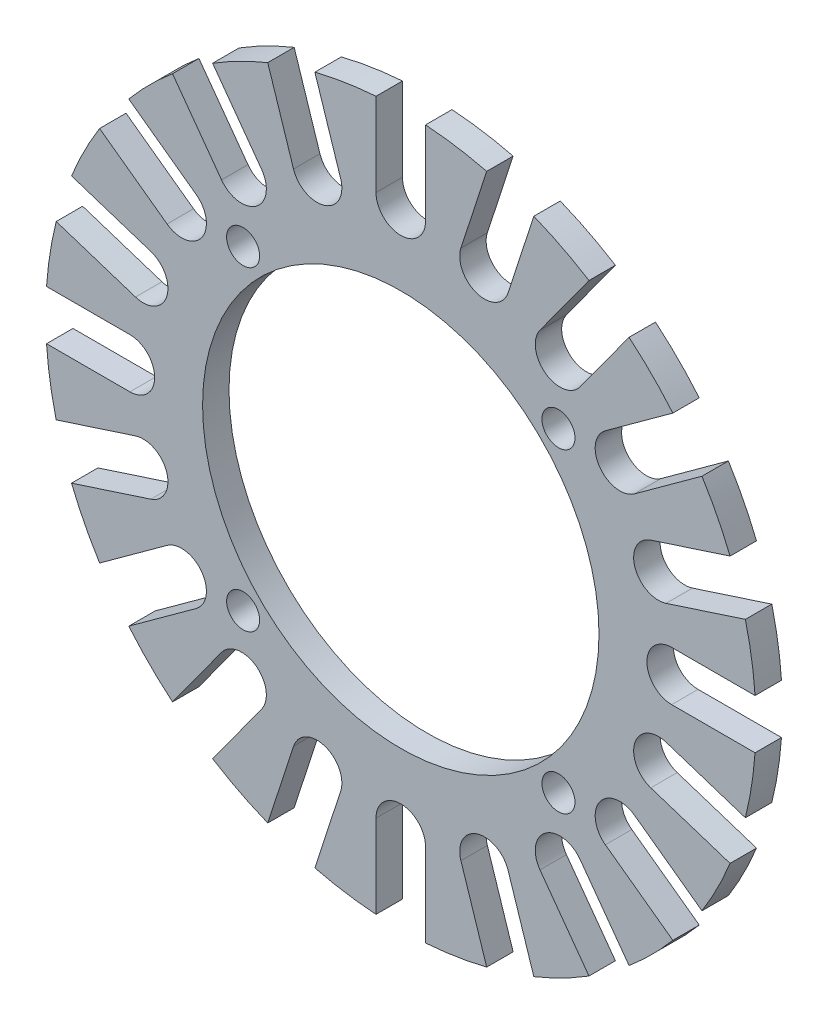
from build123d import *

# Parameters (mm, degrees)
SKETCH1_R           = 12
SKETCH1_R_2         = 1
BOSS_EXTRUDE1_DEPTH = 1.6
SKETCH2_R           = 14.9
SKETCH2_R_2         = 12
BOSS_EXTRUDE2_DEPTH = 1.6
SKETCH3_R           = 1
CUT_EXTRUDE1_DEPTH  = 10


with BuildPart() as part:
    # Sketch1 → Boss-Extrude1 (new body)
    with BuildSketch(Plane.XY):
        with BuildLine():
            Line((-1.5, 16.4), (-1.5, 21.44761059))
            ThreePointArc((-1.5, 21.44761059), (-3.363340998, 21.235299323), (-5.201091386, 20.861415302))
            Line((-5.201091386, 20.861415302), (-3.641293933, 16.060852359))
            ThreePointArc((-3.641293933, 16.060852359), (-4.604353216, 14.170742093), (-6.494463482, 15.133801376))
            Line((-6.494463482, 15.133801376), (-8.054260935, 19.934364319))
            ThreePointArc((-8.054260935, 19.934364319), (-9.760795744, 19.15664027), (-11.39306371, 18.233159334))
            Line((-11.39306371, 18.233159334), (-8.426152646, 14.149556586))
            ThreePointArc((-8.426152646, 14.149556586), (-8.758000259, 12.054353216), (-10.853203629, 12.386200829))
            Line((-10.853203629, 12.386200829), (-13.820114693, 16.469803577))
            ThreePointArc((-13.820114693, 16.469803577), (-15.202795796, 15.202795796), (-16.469803577, 13.820114693))
            Line((-16.469803577, 13.820114693), (-12.386200829, 10.853203629))
            ThreePointArc((-12.386200829, 10.853203629), (-12.054353216, 8.758000259), (-14.149556586, 8.426152646))
            Line((-14.149556586, 8.426152646), (-18.233159334, 11.39306371))
            ThreePointArc((-18.233159334, 11.39306371), (-19.15664027, 9.760795744), (-19.934364319, 8.054260935))
            Line((-19.934364319, 8.054260935), (-15.133801376, 6.494463482))
            ThreePointArc((-15.133801376, 6.494463482), (-14.170742093, 4.604353216), (-16.060852359, 3.641293933))
            Line((-16.060852359, 3.641293933), (-20.861415302, 5.201091386))
            ThreePointArc((-20.861415302, 5.201091386), (-21.235299323, 3.363340998), (-21.44761059, 1.5))
            Line((-21.44761059, 1.5), (-16.4, 1.5))
            ThreePointArc((-16.4, 1.5), (-14.9, 0), (-16.4, -1.5))
            Line((-16.4, -1.5), (-21.44761059, -1.5))
            ThreePointArc((-21.44761059, -1.5), (-21.235299323, -3.363340998), (-20.861415302, -5.201091386))
            Line((-20.861415302, -5.201091386), (-16.060852359, -3.641293933))
            ThreePointArc((-16.060852359, -3.641293933), (-14.170742093, -4.604353216), (-15.133801376, -6.494463482))
            Line((-15.133801376, -6.494463482), (-19.934364319, -8.054260935))
            ThreePointArc((-19.934364319, -8.054260935), (-19.15664027, -9.760795744), (-18.233159334, -11.39306371))
            Line((-18.233159334, -11.39306371), (-14.149556586, -8.426152646))
            ThreePointArc((-14.149556586, -8.426152646), (-12.054353216, -8.758000259), (-12.386200829, -10.853203629))
            Line((-12.386200829, -10.853203629), (-16.469803577, -13.820114693))
            ThreePointArc((-16.469803577, -13.820114693), (-15.202795796, -15.202795796), (-13.820114693, -16.469803577))
            Line((-13.820114693, -16.469803577), (-10.853203629, -12.386200829))
            ThreePointArc((-10.853203629, -12.386200829), (-8.758000259, -12.054353216), (-8.426152646, -14.149556586))
            Line((-8.426152646, -14.149556586), (-11.39306371, -18.233159334))
            ThreePointArc((-11.39306371, -18.233159334), (-9.760795744, -19.15664027), (-8.054260935, -19.934364319))
            Line((-8.054260935, -19.934364319), (-6.494463482, -15.133801376))
            ThreePointArc((-6.494463482, -15.133801376), (-4.604353216, -14.170742093), (-3.641293933, -16.060852359))
            Line((-3.641293933, -16.060852359), (-5.201091386, -20.861415302))
            ThreePointArc((-5.201091386, -20.861415302), (-3.363340998, -21.235299323), (-1.5, -21.44761059))
            Line((-1.5, -21.44761059), (-1.5, -16.4))
            ThreePointArc((-1.5, -16.4), (0, -14.9), (1.5, -16.4))
            Line((1.5, -16.4), (1.5, -21.44761059))
            ThreePointArc((1.5, -21.44761059), (3.363340998, -21.235299323), (5.201091386, -20.861415302))
            Line((5.201091386, -20.861415302), (3.641293933, -16.060852359))
            ThreePointArc((3.641293933, -16.060852359), (4.604353216, -14.170742093), (6.494463482, -15.133801376))
            Line((6.494463482, -15.133801376), (8.054260935, -19.934364319))
            ThreePointArc((8.054260935, -19.934364319), (9.760795744, -19.15664027), (11.39306371, -18.233159334))
            Line((11.39306371, -18.233159334), (8.426152646, -14.149556586))
            ThreePointArc((8.426152646, -14.149556586), (8.758000259, -12.054353216), (10.853203629, -12.386200829))
            Line((10.853203629, -12.386200829), (13.820114693, -16.469803577))
            ThreePointArc((13.820114693, -16.469803577), (15.202795796, -15.202795796), (16.469803577, -13.820114693))
            Line((16.469803577, -13.820114693), (12.386200829, -10.853203629))
            ThreePointArc((12.386200829, -10.853203629), (12.054353216, -8.758000259), (14.149556586, -8.426152646))
            Line((14.149556586, -8.426152646), (18.233159334, -11.39306371))
            ThreePointArc((18.233159334, -11.39306371), (19.15664027, -9.760795744), (19.934364319, -8.054260935))
            Line((19.934364319, -8.054260935), (15.133801376, -6.494463482))
            ThreePointArc((15.133801376, -6.494463482), (14.170742093, -4.604353216), (16.060852359, -3.641293933))
            Line((16.060852359, -3.641293933), (20.861415302, -5.201091386))
            ThreePointArc((20.861415302, -5.201091386), (21.235299323, -3.363340998), (21.44761059, -1.5))
            Line((21.44761059, -1.5), (16.4, -1.5))
            ThreePointArc((16.4, -1.5), (14.9, 0), (16.4, 1.5))
            Line((16.4, 1.5), (21.44761059, 1.5))
            ThreePointArc((21.44761059, 1.5), (21.235299323, 3.363340998), (20.861415302, 5.201091386))
            Line((20.861415302, 5.201091386), (16.060852359, 3.641293933))
            ThreePointArc((16.060852359, 3.641293933), (14.170742093, 4.604353216), (15.133801376, 6.494463482))
            Line((15.133801376, 6.494463482), (19.934364319, 8.054260935))
            ThreePointArc((19.934364319, 8.054260935), (19.15664027, 9.760795744), (18.233159334, 11.39306371))
            Line((18.233159334, 11.39306371), (14.149556586, 8.426152646))
            ThreePointArc((14.149556586, 8.426152646), (12.054353216, 8.758000259), (12.386200829, 10.853203629))
            Line((12.386200829, 10.853203629), (16.469803577, 13.820114693))
            ThreePointArc((16.469803577, 13.820114693), (15.202795796, 15.202795796), (13.820114693, 16.469803577))
            Line((13.820114693, 16.469803577), (10.853203629, 12.386200829))
            ThreePointArc((10.853203629, 12.386200829), (8.758000259, 12.054353216), (8.426152646, 14.149556586))
            Line((8.426152646, 14.149556586), (11.39306371, 18.233159334))
            ThreePointArc((11.39306371, 18.233159334), (9.760795744, 19.15664027), (8.054260935, 19.934364319))
            Line((8.054260935, 19.934364319), (6.494463482, 15.133801376))
            ThreePointArc((6.494463482, 15.133801376), (4.604353216, 14.170742093), (3.641293933, 16.060852359))
            Line((3.641293933, 16.060852359), (5.201091386, 20.861415302))
            ThreePointArc((5.201091386, 20.861415302), (3.363340998, 21.235299323), (1.5, 21.44761059))
            Line((1.5, 21.44761059), (1.5, 16.4))
            ThreePointArc((1.5, 16.4), (0, 14.9), (-1.5, 16.4))
        make_face()
        Circle(SKETCH1_R, mode=Mode.SUBTRACT)
        with Locations((0, 13.5)):
            Circle(SKETCH1_R_2, mode=Mode.SUBTRACT)
        with Locations((13.5, 0)):
            Circle(SKETCH1_R_2, mode=Mode.SUBTRACT)
        with Locations((0, -13.5)):
            Circle(SKETCH1_R_2, mode=Mode.SUBTRACT)
        with Locations((-13.5, 0)):
            Circle(SKETCH1_R_2, mode=Mode.SUBTRACT)
    extrude(amount=BOSS_EXTRUDE1_DEPTH)

    # Sketch2 → Boss-Extrude2 (add)
    with BuildSketch(Plane.XY.offset(1.6)):
        Circle(SKETCH2_R)
        Circle(SKETCH2_R_2, mode=Mode.SUBTRACT)
    extrude(amount=-BOSS_EXTRUDE2_DEPTH)

    # Sketch3 → Cut-Extrude1 (cut)
    with BuildSketch(Plane.XY.offset(1.6)):
        with Locations((9.545941546, 9.545941546)):
            Circle(SKETCH3_R)
        with Locations((9.545941546, -9.545941546)):
            Circle(SKETCH3_R)
        with Locations((-9.545941546, -9.545941546)):
            Circle(SKETCH3_R)
        with Locations((-9.545941546, 9.545941546)):
            Circle(SKETCH3_R)
    extrude(amount=-CUT_EXTRUDE1_DEPTH, mode=Mode.SUBTRACT)


solid = part.part
